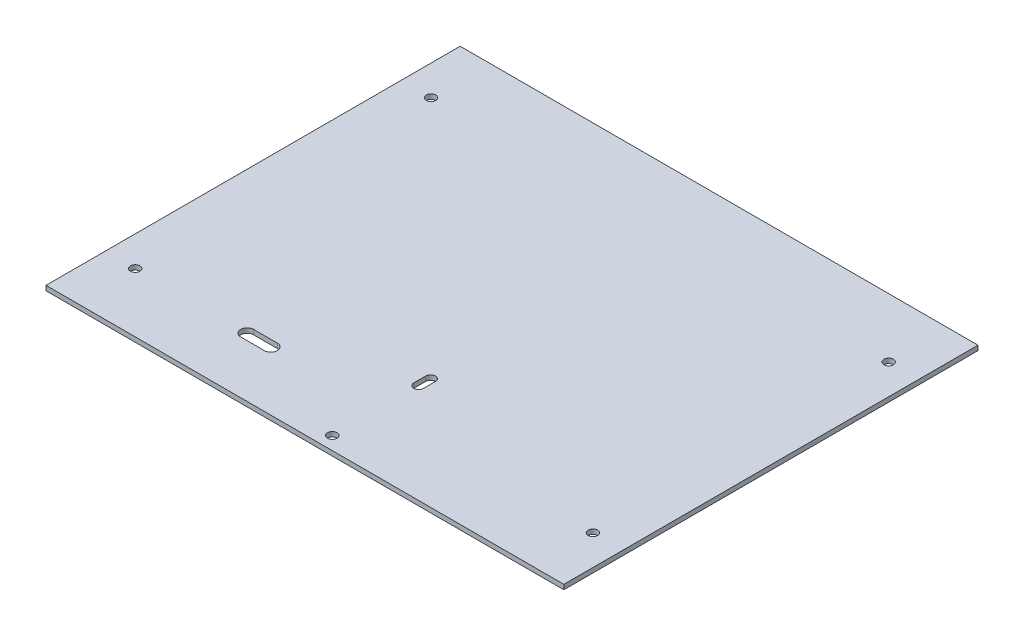
from build123d import *

# Parameters (mm, degrees)
SKETCH1_W           = 437.6
SKETCH1_H           = 350
SKETCH1_R           = 4.064
BOSS_EXTRUDE1_DEPTH = 4
SKETCH2_R           = 4
CUT_EXTRUDE1_DEPTH  = 5


with BuildPart() as part:
    # Sketch1 → Boss-Extrude1 (new body)
    with BuildSketch(Plane(origin=(0, 0, 0), x_dir=(1, 0, 0), z_dir=(0, 1, 0))):
        Rectangle(SKETCH1_W, SKETCH1_H)
        with Locations((12.044, -163.8875)):
            Circle(SKETCH1_R, mode=Mode.SUBTRACT)
        with BuildLine():
            Line((7.979, -90.8875), (7.979, -80.8875))
            ThreePointArc((7.979, -80.8875), (12.044, -76.8225), (16.109, -80.8875))
            Line((16.109, -80.8875), (16.109, -90.8875))
            ThreePointArc((16.109, -90.8875), (12.044, -94.9525), (7.979, -90.8875))
        make_face(mode=Mode.SUBTRACT)
    extrude(amount=BOSS_EXTRUDE1_DEPTH)

    # Sketch2 → Cut-Extrude1 (cut, through all)
    with BuildSketch(Plane(origin=(0, 4, 0), x_dir=(1, 0, 0), z_dir=(0, 1, 0))):
        with Locations((-193.4, 125)):
            Circle(SKETCH2_R)
        with Locations((-193.4, -125)):
            Circle(SKETCH2_R)
        with Locations((193.4, -125)):
            Circle(SKETCH2_R)
        with Locations((193.4, 125)):
            Circle(SKETCH2_R)
        with BuildLine():
            Line((-98.8, -119.5), (-78.8, -119.5))
            ThreePointArc((-78.8, -119.5), (-73.3, -125), (-78.8, -130.5))
            Line((-78.8, -130.5), (-98.8, -130.5))
            ThreePointArc((-98.8, -130.5), (-104.3, -125), (-98.8, -119.5))
        make_face()
    extrude(amount=-CUT_EXTRUDE1_DEPTH, mode=Mode.SUBTRACT)


solid = part.part
